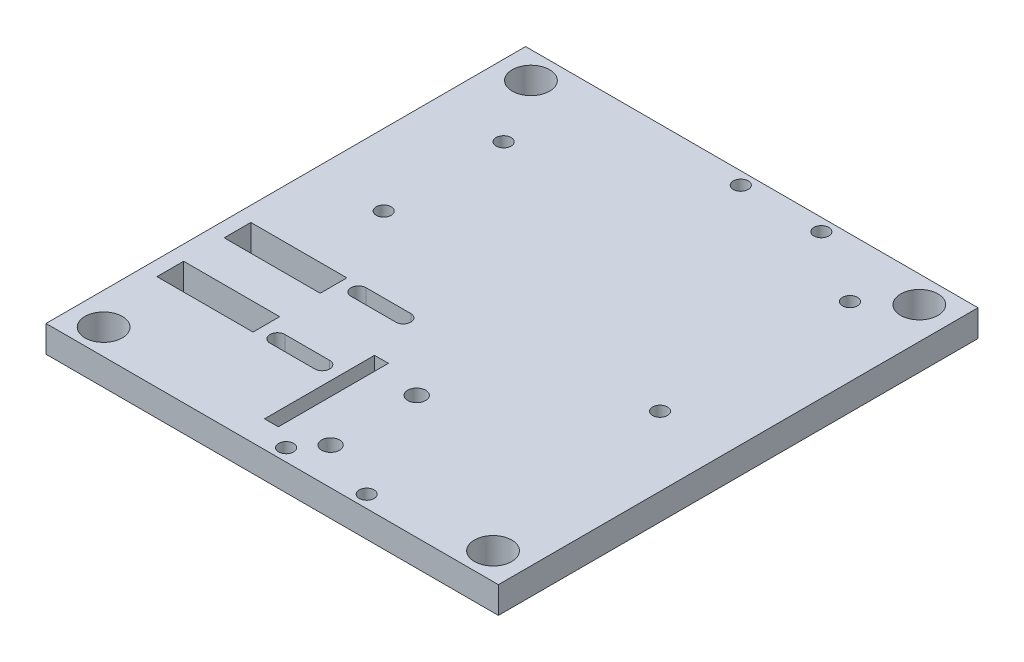
from build123d import *

# Parameters (mm, degrees)
ESQUISSE1_W             = 107.696
ESQUISSE1_H             = 114.173
BOSS_EXTRU_1_DEPTH      = 6.35
ESQUISSE1_6_OUTSIDE_W   = 141.112
ESQUISSE1_6_OUTSIDE_H   = 147.588
ESQUISSE1_6_OUTSIDE_W_2 = 107.696
ESQUISSE1_6_OUTSIDE_H_2 = 114.173
ESQUISSE1_6_OUTSIDE_R   = 1.778
ESQUISSE1_6_OUTSIDE_R_2 = 4.445
ESQUISSE1_6_OUTSIDE_W_3 = 3.302
ESQUISSE1_6_OUTSIDE_H_3 = 25.4
ESQUISSE1_6_OUTSIDE_W_4 = 22.86
ESQUISSE1_6_OUTSIDE_H_4 = 6.35
ENL_V_MAT_EXTRU_3_DEPTH = 7.35
ESQUISSE2_R             = 1.778
BOSS_EXTRU_2_DEPTH      = 6.35
ESQUISSE3_R             = 2.135000048
ESQUISSE3_W             = 3.302
ESQUISSE3_H             = 0.79375
ENL_V_MAT_EXTRU_4_DEPTH = 7.35


with BuildPart() as part:
    # Esquisse1 → Boss.-Extru.1 (new body)
    with BuildSketch(Plane(origin=(0, 0, 0), x_dir=(1, 0, 0), z_dir=(0, 1, 0))):
        Rectangle(ESQUISSE1_W, ESQUISSE1_H)
    extrude(amount=BOSS_EXTRU_1_DEPTH)

    # Esquisse1_6 outside → Enlèv. mat.-Extru.3 (cut, through all)
    with BuildSketch(Plane(origin=(0, 0, 0), x_dir=(1, 0, 0), z_dir=(0, 1, 0))):
        Rectangle(ESQUISSE1_6_OUTSIDE_W, ESQUISSE1_6_OUTSIDE_H)
        Rectangle(ESQUISSE1_6_OUTSIDE_W_2, ESQUISSE1_6_OUTSIDE_H_2, mode=Mode.SUBTRACT)
        with Locations((0.3429, -54.1147)):
            Circle(ESQUISSE1_6_OUTSIDE_R)
        with Locations((19.5199, -54.1147)):
            Circle(ESQUISSE1_6_OUTSIDE_R)
        with Locations((6.858, -49.9745)):
            Circle(ESQUISSE1_6_OUTSIDE_R)
        with Locations((6.858, -30.6705)):
            Circle(ESQUISSE1_6_OUTSIDE_R)
        with Locations((-4.572, -23.0505)):
            Circle(ESQUISSE1_6_OUTSIDE_R)
        with Locations((46.228, -50.7365)):
            Circle(ESQUISSE1_6_OUTSIDE_R_2)
        with Locations((46.228, 50.7365)):
            Circle(ESQUISSE1_6_OUTSIDE_R_2)
        with Locations((37.338, 43.1165)):
            Circle(ESQUISSE1_6_OUTSIDE_R)
        with Locations((37.338, -2.0955)):
            Circle(ESQUISSE1_6_OUTSIDE_R)
        with Locations((-36.83, 34.8361)):
            Circle(ESQUISSE1_6_OUTSIDE_R)
        with Locations((-36.83, 6.2865)):
            Circle(ESQUISSE1_6_OUTSIDE_R)
        with Locations((19.5199, 54.1147)):
            Circle(ESQUISSE1_6_OUTSIDE_R)
        with Locations((0.3429, 54.1147)):
            Circle(ESQUISSE1_6_OUTSIDE_R)
        with Locations((-46.228, 50.7365)):
            Circle(ESQUISSE1_6_OUTSIDE_R_2)
        with Locations((-46.228, -50.9905)):
            Circle(ESQUISSE1_6_OUTSIDE_R_2)
        with Locations((-6.5278, -38.0365)):
            Rectangle(ESQUISSE1_6_OUTSIDE_W_3, ESQUISSE1_6_OUTSIDE_H_3)
        with Locations((-38.862, -15.0495)):
            Rectangle(ESQUISSE1_6_OUTSIDE_W_4, ESQUISSE1_6_OUTSIDE_H_4)
        with Locations((-38.862, -31.0515)):
            Rectangle(ESQUISSE1_6_OUTSIDE_W_4, ESQUISSE1_6_OUTSIDE_H_4)
        with BuildLine():
            Line((-23.1394, -34.4805), (-12.4714, -34.4805))
            ThreePointArc((-12.4714, -34.4805), (-10.6934, -32.7025), (-12.4714, -30.9245))
            Line((-12.4714, -30.9245), (-23.1394, -30.9245))
            ThreePointArc((-23.1394, -30.9245), (-24.9174, -32.7025), (-23.1394, -34.4805))
        make_face()
        with BuildLine():
            Line((-23.1394, -15.1765), (-12.4714, -15.1765))
            ThreePointArc((-12.4714, -15.1765), (-10.6934, -13.3985), (-12.4714, -11.6205))
            Line((-12.4714, -11.6205), (-23.1394, -11.6205))
            ThreePointArc((-23.1394, -11.6205), (-24.9174, -13.3985), (-23.1394, -15.1765))
        make_face()
    extrude(amount=ENL_V_MAT_EXTRU_3_DEPTH, mode=Mode.SUBTRACT)

    # Esquisse2 → Boss.-Extru.2 (add)
    with BuildSketch(Plane(origin=(0, 6.35, 0), x_dir=(1, 0, 0), z_dir=(0, 1, 0))):
        with Locations((-4.572, -23.0505)):
            Circle(ESQUISSE2_R)
        with Locations((6.858, -30.6705)):
            Circle(ESQUISSE2_R)
        with Locations((6.858, -49.9745)):
            Circle(ESQUISSE2_R)
    extrude(amount=-BOSS_EXTRU_2_DEPTH)

    # Esquisse3 → Enlèv. mat.-Extru.4 (cut, through all)
    with BuildSketch(Plane(origin=(0, 6.35, 0), x_dir=(1, 0, 0), z_dir=(0, 1, 0))):
        with Locations((5.0992, -27.7865)):
            Circle(ESQUISSE3_R)
        with Locations((5.0992, -48.2865)):
            Circle(ESQUISSE3_R)
        with Locations((-6.5278, -24.939625)):
            Rectangle(ESQUISSE3_W, ESQUISSE3_H)
    extrude(amount=-ENL_V_MAT_EXTRU_4_DEPTH, mode=Mode.SUBTRACT)


solid = part.part
